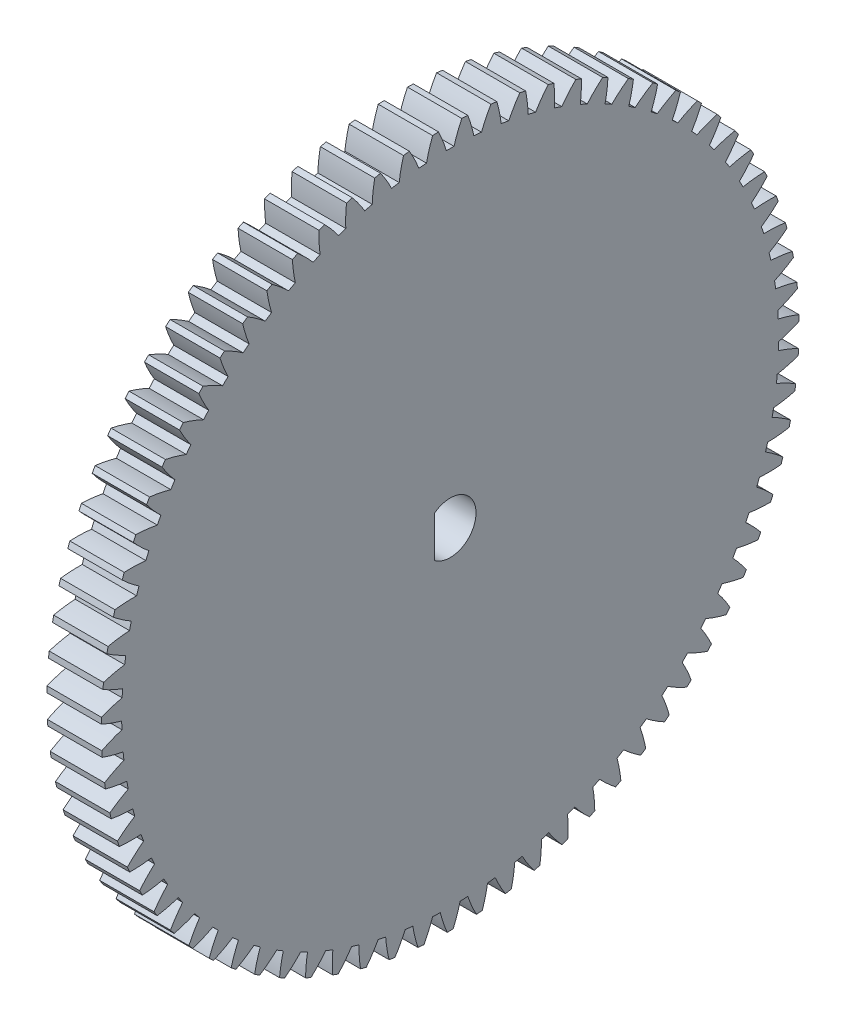
from build123d import *

# Parameters (mm, degrees)
BASPROSKE_W        = 6
BASPROSKE_H        = 38.5
TOOTHCUT_DEPTH     = 55.776819915
TEETHCUTS_COUNT    = 75
TEETHCUTS_ANGLE    = 355.2
CUT_EXTRUDE3_DEPTH = 55.774735489


with BuildPart() as part:
    # BasProSke → Base-Revolve (revolve)
    with BuildSketch(Plane(origin=(0, 0, 0), x_dir=(1, 0, 0), z_dir=(0, 1, 0)), mode=Mode.PRIVATE) as base_revolve_sk:
        with Locations((3, 19.25)):
            Rectangle(BASPROSKE_W, BASPROSKE_H)
    revolve(base_revolve_sk.sketch.rotate(Axis((-10, 0, 0), (1, 0, 0)), 180), axis=Axis((-10, 0, 0), (1, 0, 0)))

    # TooCutSke → ToothCut (cut, through all)
    with BuildSketch(Plane(origin=(0, 0, 0), x_dir=(0, 0, -1), z_dir=(1, 0, 0))):
        with BuildLine():
            ThreePointArc((0.422493895, 36.246537764), (0, 36.249), (-0.422493895, 36.246537764))
            ThreePointArc((-0.422493895, 36.246537764), (-0.813667594, 37.392712423), (-1.296032055, 38.503593937))
            ThreePointArc((-1.296032055, 38.503593937), (0, 38.5254), (1.296032055, 38.503593937))
            ThreePointArc((1.296032055, 38.503593937), (0.813667594, 37.392712423), (0.422493895, 36.246537764))
        make_face()
    toothcut = extrude(amount=TOOTHCUT_DEPTH, mode=Mode.SUBTRACT)

    # TeethCuts: ToothCut ×75 about axis
    teethcuts_axis = Axis((-10, 0, 0), (1, 0, 0))
    for i in range(1, TEETHCUTS_COUNT):
        add(toothcut.rotate(teethcuts_axis, i * TEETHCUTS_ANGLE / (TEETHCUTS_COUNT - 1)), mode=Mode.SUBTRACT)

    # Sketch2 → Cut-Extrude3 (cut, through all)
    with BuildSketch(Plane(origin=(6, 0, 0), x_dir=(0, 0, -1), z_dir=(1, 0, 0))):
        with BuildLine():
            Line((-1.749285568, 2.25), (-1.749285568, -2.25))
            ThreePointArc((-1.749285568, -2.25), (2.85, 0), (-1.749285568, 2.25))
        make_face()
    extrude(amount=-CUT_EXTRUDE3_DEPTH, mode=Mode.SUBTRACT)


solid = part.part
